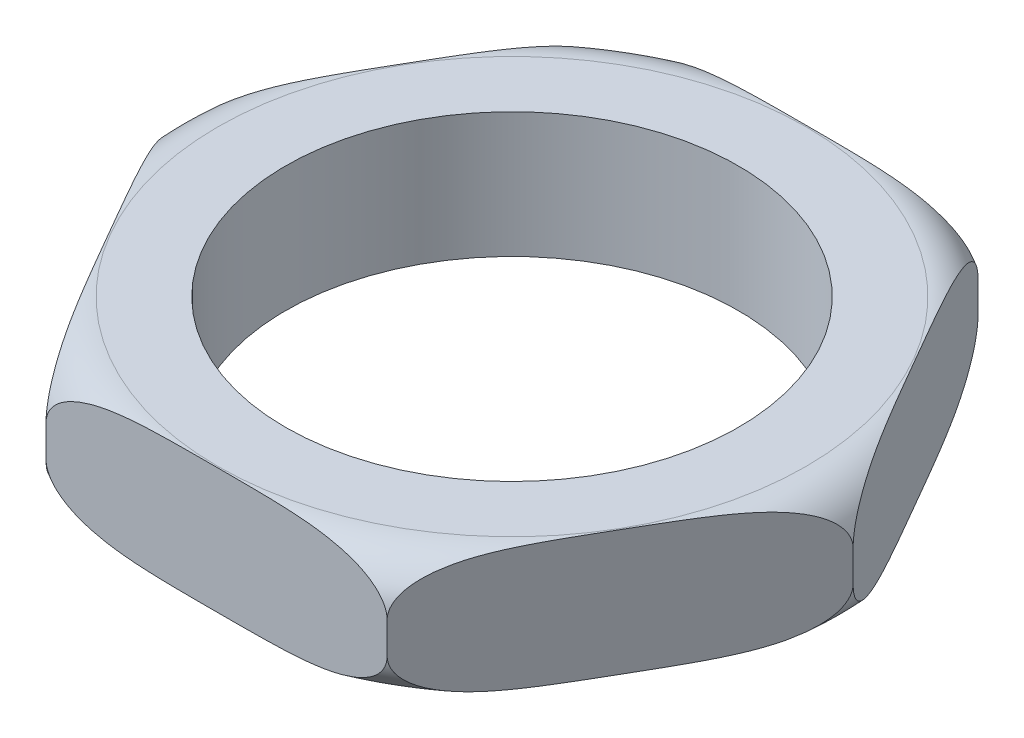
from build123d import *

# Parameters (mm, degrees)
SKETCH1_R           = 3.6703
BOSS_EXTRUDE1_DEPTH = 2.032


with BuildPart() as part:
    # Sketch1 → Boss-Extrude1 (new body)
    with BuildSketch(Plane(origin=(0, 0, 0), x_dir=(1, 0, 0), z_dir=(0, 1, 0))):
        Polygon((-2.764295354, 4.7879), (-5.528590708, 0), (-2.764295354, -4.7879), (2.764295354, -4.7879), (5.528590708, 0), (2.764295354, 4.7879), align=None)
        Circle(SKETCH1_R, mode=Mode.SUBTRACT)
    extrude(amount=BOSS_EXTRUDE1_DEPTH)

    # Sketch2 → Cut-Revolve1 (revolve, cut)
    with BuildSketch(Plane.XY):
        with BuildLine():
            Line((4.766590708, 2.032), (5.528590708, 2.032))
            Line((5.528590708, 2.032), (5.528590708, 1.27))
            ThreePointArc((5.528590708, 1.27), (5.305406075, 1.808815367), (4.766590708, 2.032))
        make_face()
        with BuildLine():
            Line((4.766590708, 0), (5.528590708, 0))
            Line((5.528590708, 0), (5.528590708, 0.762))
            ThreePointArc((5.528590708, 0.762), (5.305406075, 0.223184633), (4.766590708, 0))
        make_face()
    revolve(axis=Axis((0, 0, 0), (0, 1, 0)), mode=Mode.SUBTRACT)


solid = part.part
